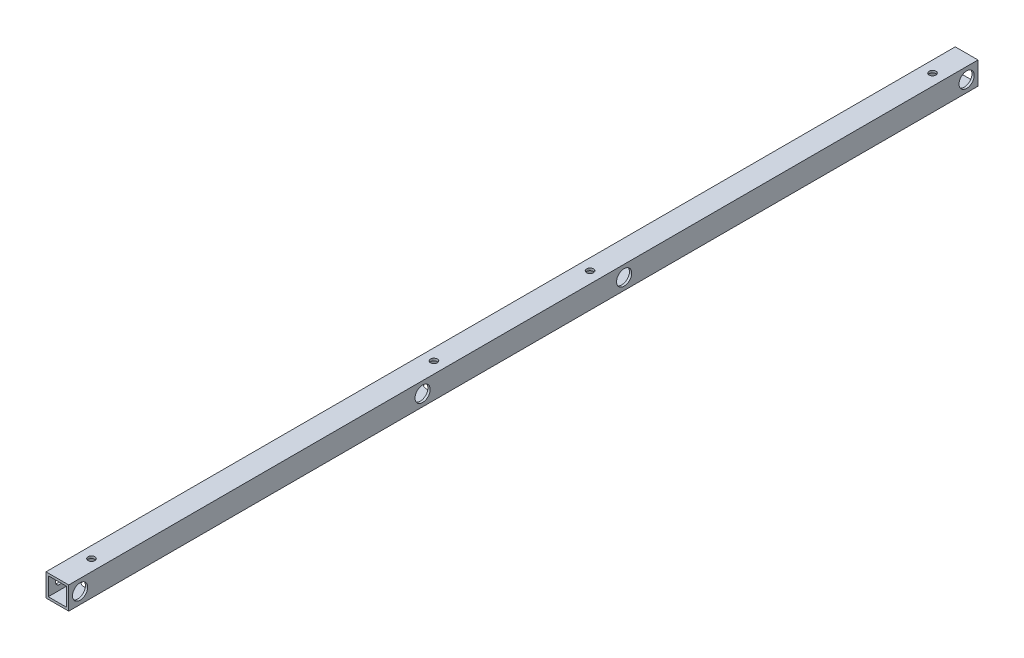
from build123d import *

# Parameters (mm, degrees)
SKETCH_1_W          = 15
SKETCH_1_H          = 15
SKETCH_1_W_2        = 12
SKETCH_1_H_2        = 12
EXTRUDE_1_DEPTH     = 600
SKETCH_2_R          = 2.7
CUT_EXTRUDE_1_DEPTH = 25
SKETCH_3_R          = 2.25
CUT_EXTRUDE_2_DEPTH = 25
SKETCH_4_R          = 2.7
CUT_EXTRUDE_3_DEPTH = 20
SKETCH_5_R          = 5
CUT_EXTRUDE_4_DEPTH = 10
SKETCH_6_R          = 5
CUT_EXTRUDE_5_DEPTH = 10


with BuildPart() as part:
    # ｽｹｯﾁ1 → ﾎﾞｽ - 押し出し1 (new body)
    with BuildSketch(Plane.XY):
        Rectangle(SKETCH_1_W, SKETCH_1_H)
        Rectangle(SKETCH_1_W_2, SKETCH_1_H_2, mode=Mode.SUBTRACT)
    extrude(amount=EXTRUDE_1_DEPTH)

    # ｽｹｯﾁ2 → ｶｯﾄ - 押し出し1 (cut)
    with BuildSketch(Plane(origin=(7.5, 0, 0), x_dir=(0, 0, -1), z_dir=(1, 0, 0))):
        with Locations((-592.5, 0)):
            Circle(SKETCH_2_R)
        with Locations((-7.5, 0)):
            Circle(SKETCH_2_R)
    extrude(amount=-CUT_EXTRUDE_1_DEPTH, mode=Mode.SUBTRACT)

    # ｽｹｯﾁ3 → ｶｯﾄ - 押し出し2 (cut)
    with BuildSketch(Plane(origin=(0, 7.5, 0), x_dir=(1, 0, 0), z_dir=(0, 1, 0))):
        with Locations((0, -22.5)):
            Circle(SKETCH_3_R)
        with Locations((0, -577.5)):
            Circle(SKETCH_3_R)
        with Locations((0, -248.5)):
            Circle(SKETCH_3_R)
        with Locations((0, -351.5)):
            Circle(SKETCH_3_R)
    extrude(amount=-CUT_EXTRUDE_2_DEPTH, mode=Mode.SUBTRACT)

    # ｽｹｯﾁ4 → ｶｯﾄ - 押し出し3 (cut)
    with BuildSketch(Plane(origin=(7.5, 0, 0), x_dir=(0, 0, -1), z_dir=(1, 0, 0))):
        with Locations((-366.5, 0)):
            Circle(SKETCH_4_R)
        with Locations((-233.5, 0)):
            Circle(SKETCH_4_R)
    extrude(amount=-CUT_EXTRUDE_3_DEPTH, mode=Mode.SUBTRACT)

    # ｽｹｯﾁ5 → ｶｯﾄ - 押し出し4 (cut)
    with BuildSketch(Plane(origin=(7.5, 0, 0), x_dir=(0, 0, -1), z_dir=(1, 0, 0))):
        with Locations((-592.5, 0)):
            Circle(SKETCH_5_R)
        with Locations((-366.5, 0)):
            Circle(SKETCH_5_R)
        with Locations((-233.5, 0)):
            Circle(SKETCH_5_R)
        with Locations((-7.5, 0)):
            Circle(SKETCH_5_R)
    extrude(amount=-CUT_EXTRUDE_4_DEPTH, mode=Mode.SUBTRACT)

    # ｽｹｯﾁ6 → ｶｯﾄ - 押し出し5 (cut)
    with BuildSketch(Plane(origin=(0, -7.5, 0), x_dir=(-1, 0, 0), z_dir=(0, -1, 0))):
        with Locations((0, -577.5)):
            Circle(SKETCH_6_R)
        with Locations((0, -22.5)):
            Circle(SKETCH_6_R)
        with Locations((0, -248.5)):
            Circle(SKETCH_6_R)
        with Locations((0, -351.5)):
            Circle(SKETCH_6_R)
    extrude(amount=-CUT_EXTRUDE_5_DEPTH, mode=Mode.SUBTRACT)


solid = part.part
